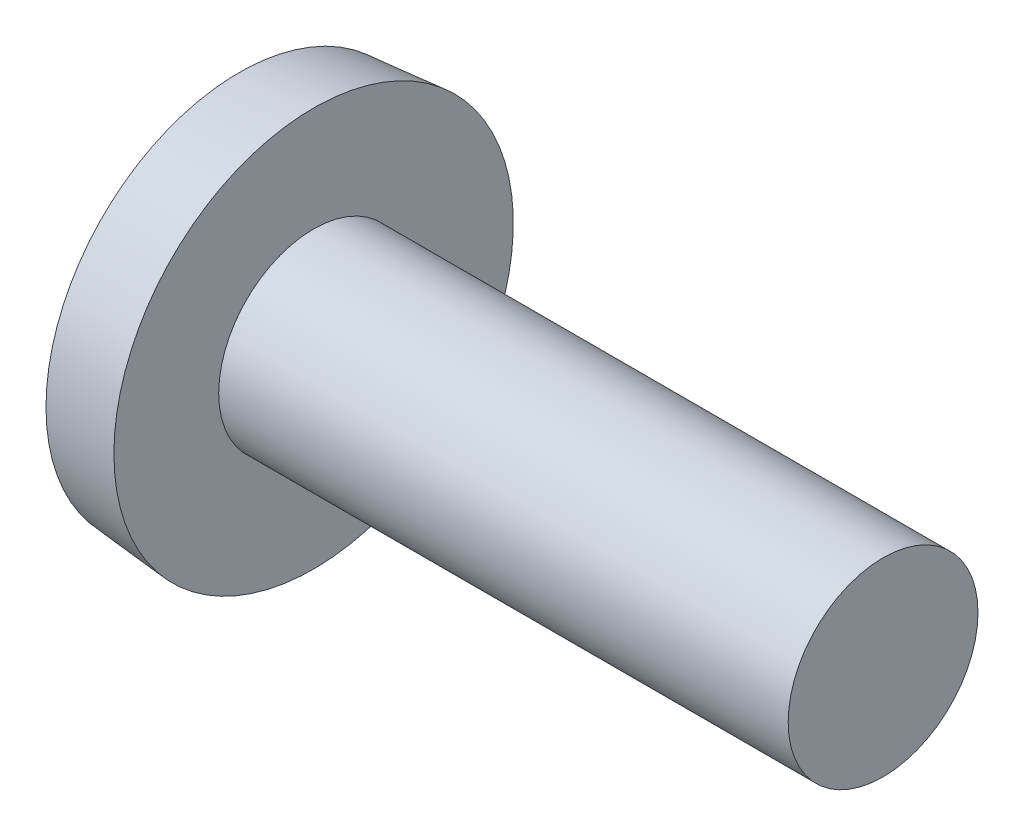
from build123d import *

# Parameters (mm, degrees)
SKETCH3_W         = 0.9144
SKETCH3_H         = 4.3688
SKETCH4_W         = 0.4572
SKETCH4_H         = 0.4572
CIRPATTERN1_COUNT = 2
CIRPATTERN1_ANGLE = 90


with BuildPart() as part:
    # BodySke → Base-Revolve (revolve)
    with BuildSketch(Plane.XY):
        with BuildLine():
            Line((1.9812, 1.5875), (1.9812, 3.3401))
            Line((1.9812, 3.3401), (0.7366, 3.231211609))
            ThreePointArc((0.7366, 3.231211609), (0.186482241, 1.657053713), (0, 0))
            Line((0, 0), (11.5062, 0))
            Line((11.5062, 0), (11.5062, 1.5875))
            Line((11.5062, 1.5875), (1.9812, 1.5875))
        make_face()
    revolve(axis=Axis((-25.4, 0, 0), (1, 0, 0)))

    # Sketch3 → Cross section 0
    with BuildSketch(Plane(origin=(0, 0, 0), x_dir=(0, 0, -1), z_dir=(1, 0, 0))):
        Rectangle(SKETCH3_W, SKETCH3_H)
    # Sketch4 → Cross section 1
    with BuildSketch(Plane(origin=(2.4892, 0, 0), x_dir=(0, 0, -1), z_dir=(1, 0, 0))):
        Rectangle(SKETCH4_W, SKETCH4_H)
    cross = loft(mode=Mode.SUBTRACT)

    # CirPattern1: Cross ×2 about axis
    cirpattern1_axis = Axis((0, 0, 0), (1, 0, 0))
    for i in range(1, CIRPATTERN1_COUNT):
        add(cross.rotate(cirpattern1_axis, i * CIRPATTERN1_ANGLE / (CIRPATTERN1_COUNT - 1)), mode=Mode.SUBTRACT)


solid = part.part
